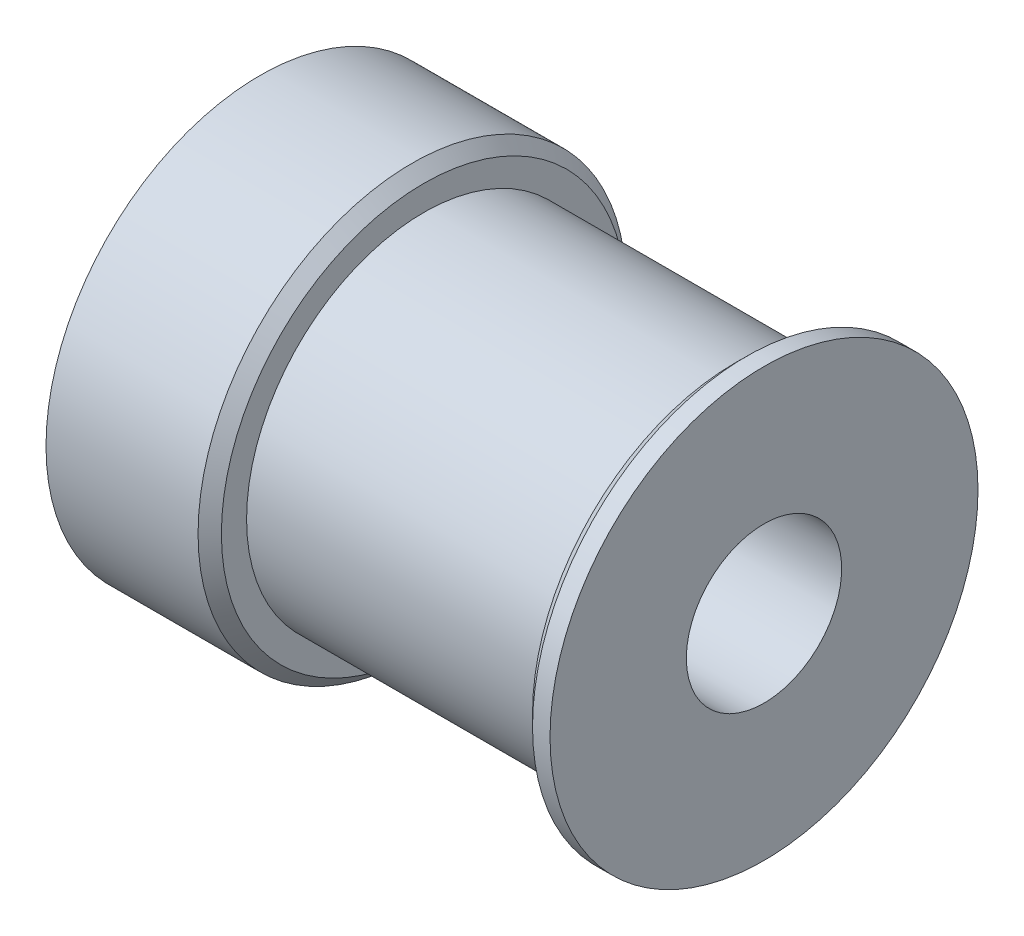
from build123d import *

# Parameters (mm, degrees)
SKETCH2_R          = 1.75
CUT_EXTRUDE1_DEPTH = 17
CIRPATTERN1_COUNT  = 2
CIRPATTERN1_ANGLE  = 90
CHAMFER1_SIZE      = 0.6


with BuildPart() as part:
    # Sketch1 → Revolve1 (revolve)
    with BuildSketch(Plane.XY):
        Polygon((-10.58638484, 3.995), (-7.464927114, 3.995), (-1.431661808, 3.995), (15.33361516, 3.995), (15.33361516, 11.005), (13.83361516, 11.005), (13.83361516, 9.11), (-2.16638484, 9.11), (-2.16638484, 11.005), (-10.58638484, 11.005), align=None)
    revolve(axis=Axis((0, 0, 0), (1, 0, 0)))

    # Sketch2 → Cut-Extrude1 (cut)
    with BuildSketch(Plane.XY):
        with Locations((-6.37638484, 0)):
            Circle(SKETCH2_R)
    cut_extrude1 = extrude(amount=-CUT_EXTRUDE1_DEPTH, mode=Mode.SUBTRACT)

    # CirPattern1: Cut-Extrude1 ×2 about axis
    cirpattern1_axis = Axis((-10.58638484, 0, 0), (-1, 0, 0))
    for i in range(1, CIRPATTERN1_COUNT):
        add(cut_extrude1.rotate(cirpattern1_axis, i * CIRPATTERN1_ANGLE / (CIRPATTERN1_COUNT - 1)), mode=Mode.SUBTRACT)

    # Chamfer1
    chamfer1_edges = [part.edges().sort_by_distance(p)[0] for p in [
        (-2.16638484, -11.005, 0),
        (13.83361516, -11.005, 0),
    ]]
    chamfer(chamfer1_edges, length=CHAMFER1_SIZE)


solid = part.part
